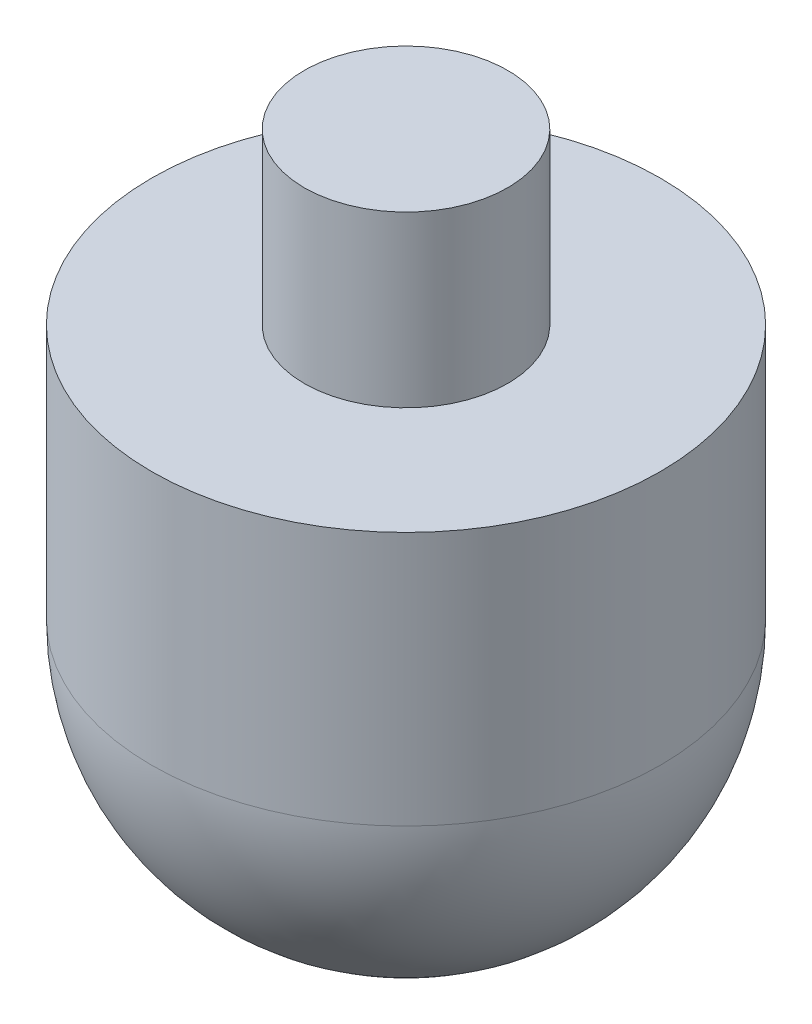
from build123d import *


with BuildPart() as part:
    # Sketch1 → Revolve2 (revolve)
    with BuildSketch(Plane.XY, mode=Mode.PRIVATE) as revolve2_sk:
        with BuildLine():
            Line((15, -25), (15, -10))
            Line((15, -10), (6, -10))
            Line((6, -10), (6, 0))
            Line((6, 0), (0, 0))
            Line((0, 0), (0, -40))
            ThreePointArc((0, -40), (10.606601718, -35.606601718), (15, -25))
        make_face()
    revolve(revolve2_sk.sketch.rotate(Axis((0, 88.322727273, 0), (0, -1, 0)), 90), axis=Axis((0, 88.322727273, 0), (0, -1, 0)))  # turned: the seam where the file's is


solid = part.part
